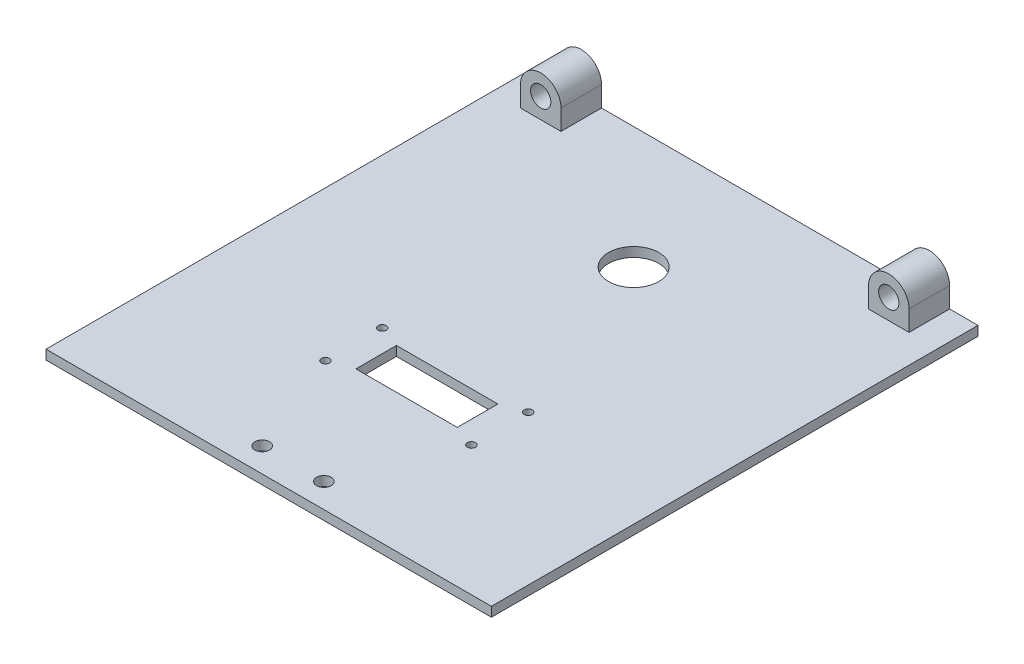
from build123d import *

# Parameters (mm, degrees)
SKETCH1_W               = 139.5
SKETCH1_H               = 152.4
BOSS_EXTRUDE1_DEPTH     = 6.35
SKETCH2_W               = 139.5
SKETCH2_H               = 152.4
CUT_EXTRUDE1_DEPTH      = 3.375
SKETCH4_R               = 3.175000001
SKETCH4_R_2             = 3.175
BOSS_EXTRUDE3_DEPTH     = 12.7
SKETCH5_R               = 7.874
CUT_EXTRUDE2_DEPTH      = 16.675
SKETCH6_R               = 2.286
CUT_EXTRUDE3_DEPTH      = 3.975
SKETCH7_R               = 1.27
SKETCH7_W               = 31.75
SKETCH7_H               = 12.7
CUT_EXTRUDE4_DEPTH      = 1
CUT_EXTRUDE4_DEPTH_BACK = 16.675


with BuildPart() as part:
    # Sketch1 → Boss-Extrude1 (new body)
    with BuildSketch(Plane(origin=(0, 0, 0), x_dir=(1, 0, 0), z_dir=(0, 1, 0))):
        with Locations((69.75, 76.2)):
            Rectangle(SKETCH1_W, SKETCH1_H)
    extrude(amount=BOSS_EXTRUDE1_DEPTH)

    # Sketch2 → Cut-Extrude1 (cut)
    with BuildSketch(Plane(origin=(0, 6.35, 0), x_dir=(1, 0, 0), z_dir=(0, 1, 0))):
        with Locations((69.75, 76.2)):
            Rectangle(SKETCH2_W, SKETCH2_H)
    extrude(amount=-CUT_EXTRUDE1_DEPTH, mode=Mode.SUBTRACT)

    # Sketch4 → Boss-Extrude3 (add)
    with BuildSketch(Plane(origin=(0, 0, -152.4), x_dir=(-1, 0, 0), z_dir=(0, 0, -1))):
        with BuildLine():
            Line((-130.61, 9.325), (-130.61, 2.975))
            Line((-130.61, 2.975), (-117.91, 2.975))
            Line((-117.91, 2.975), (-117.91, 9.325))
            ThreePointArc((-117.91, 9.325), (-124.26, 15.675), (-130.61, 9.325))
        make_face()
        with Locations((-124.26, 9.325)):
            Circle(SKETCH4_R, mode=Mode.SUBTRACT)
        with BuildLine():
            Line((-21.59, 9.325), (-21.59, 2.975))
            Line((-21.59, 2.975), (-8.89, 2.975))
            Line((-8.89, 2.975), (-8.89, 9.325))
            ThreePointArc((-8.89, 9.325), (-15.24, 15.675), (-21.59, 9.325))
        make_face()
        with Locations((-15.24, 9.325)):
            Circle(SKETCH4_R_2, mode=Mode.SUBTRACT)
    extrude(amount=-BOSS_EXTRUDE3_DEPTH)

    # Sketch5 → Cut-Extrude2 (cut, through all)
    with BuildSketch(Plane.XZ):
        with Locations((69.75, -114.3)):
            Circle(SKETCH5_R)
    extrude(amount=-CUT_EXTRUDE2_DEPTH, mode=Mode.SUBTRACT)

    # Sketch6 → Cut-Extrude3 (cut, through all)
    with BuildSketch(Plane(origin=(0, 2.975, 0), x_dir=(1, 0, 0), z_dir=(0, 1, 0))):
        with Locations((60.098, 7.62)):
            Circle(SKETCH6_R)
        with Locations((79.402, 7.62)):
            Circle(SKETCH6_R)
    extrude(amount=-CUT_EXTRUDE3_DEPTH, mode=Mode.SUBTRACT)

    # Sketch7 → Cut-Extrude4 (cut, two sides)
    with BuildSketch(Plane.XZ) as cut_extrude4_sk:
        with Locations((46.89, -40.64)):
            Circle(SKETCH7_R)
        with Locations((92.61, -40.64)):
            Circle(SKETCH7_R)
        with Locations((92.61, -58.42)):
            Circle(SKETCH7_R)
        with Locations((46.89, -58.42)):
            Circle(SKETCH7_R)
        with Locations((69.75, -49.53)):
            Rectangle(SKETCH7_W, SKETCH7_H)
    extrude(amount=CUT_EXTRUDE4_DEPTH, mode=Mode.SUBTRACT)
    extrude(cut_extrude4_sk.sketch, amount=-CUT_EXTRUDE4_DEPTH_BACK, mode=Mode.SUBTRACT)


solid = part.part
